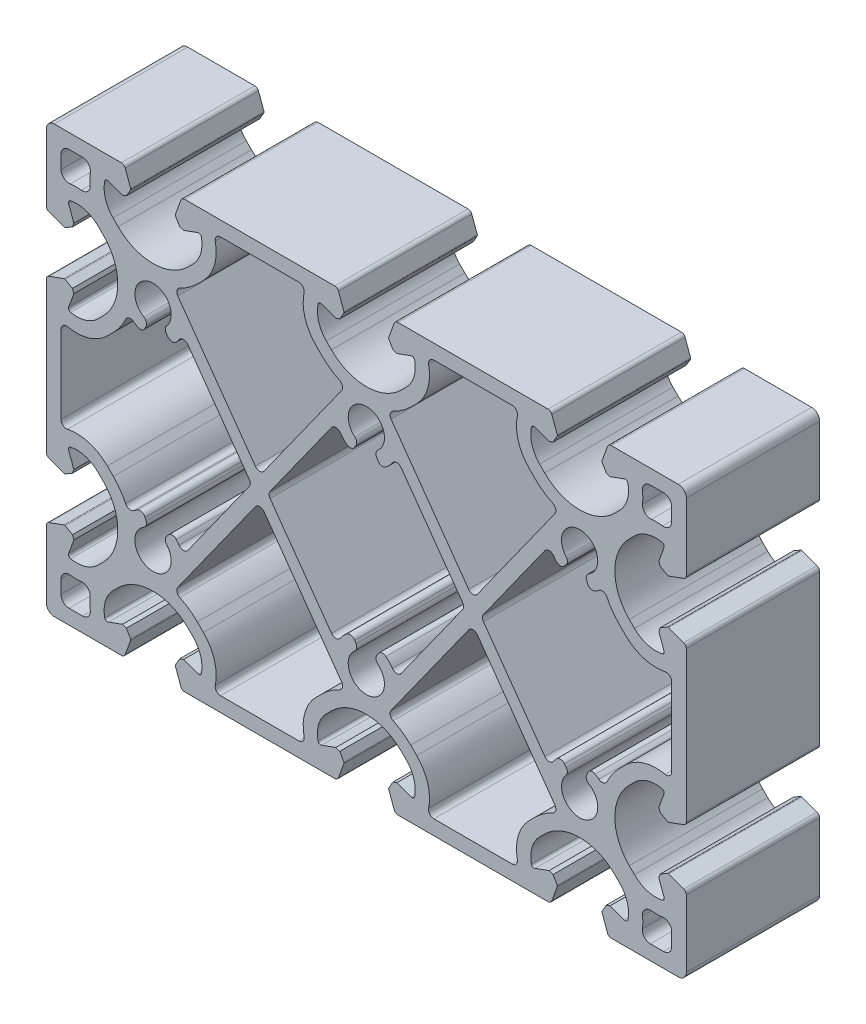
from build123d import *

# Parameters (mm, degrees)
MAIN_EXTRUSION_DEPTH = 25


with BuildPart() as part:
    # Sk Main Extrusion → Main Extrusion (new body)
    with BuildSketch(Plane.XY):
        with BuildLine():
            Line((-35.809923155, -36.671180212), (-34.777945649, -39.506515107))
            ThreePointArc((-34.777945649, -39.506515107), (-34.503358511, -39.864364033), (-34.073176184, -40))
            Line((-34.073176184, -40), (-5.926823816, -40))
            ThreePointArc((-5.926823816, -40), (-5.496641489, -39.864364033), (-5.222054351, -39.506515107))
            Line((-5.222054351, -39.506515107), (-4.190076845, -36.671180212))
            ThreePointArc((-4.190076845, -36.671180212), (-4.175951325, -36.563886241), (-4.208493649, -36.460675177))
            Line((-4.208493649, -36.460675177), (-4.987558066, -35.111296024))
            Line((-4.987558066, -35.111296024), (-5.718509166, -34.845251581))
            Line((-5.718509166, -34.845251581), (-8.396186179, -35.81984631))
            ThreePointArc((-8.396186179, -35.81984631), (-8.811074612, -35.786489799), (-9.056960151, -35.450654467))
            ThreePointArc((-9.056960151, -35.450654467), (-8.933433013, -32.665882372), (-7.504160339, -30.272684887))
            Line((-7.504160339, -30.272684887), (-6.540737726, -29.309262274))
            ThreePointArc((-6.540737726, -29.309262274), (0, -26.6), (6.540737726, -29.309262274))
            Line((6.540737726, -29.309262274), (7.504160339, -30.272684887))
            ThreePointArc((7.504160339, -30.272684887), (8.933433013, -32.665882372), (9.056960151, -35.450654467))
            ThreePointArc((9.056960151, -35.450654467), (8.811074612, -35.786489799), (8.396186179, -35.81984631))
            Line((8.396186179, -35.81984631), (5.718509166, -34.845251581))
            Line((5.718509166, -34.845251581), (4.987558066, -35.111296024))
            Line((4.987558066, -35.111296024), (4.208493649, -36.460675177))
            ThreePointArc((4.208493649, -36.460675177), (4.175951325, -36.563886241), (4.190076845, -36.671180212))
            Line((4.190076845, -36.671180212), (5.222054351, -39.506515107))
            ThreePointArc((5.222054351, -39.506515107), (5.496641489, -39.864364033), (5.926823816, -40))
            Line((5.926823816, -40), (34.073176184, -40))
            ThreePointArc((34.073176184, -40), (34.503358511, -39.864364033), (34.777945649, -39.506515107))
            Line((34.777945649, -39.506515107), (35.809923155, -36.671180212))
            ThreePointArc((35.809923155, -36.671180212), (35.824048675, -36.563886241), (35.791506351, -36.460675176))
            Line((35.791506351, -36.460675176), (35.012441934, -35.111296024))
            Line((35.012441934, -35.111296024), (34.281490834, -34.845251581))
            Line((34.281490834, -34.845251581), (31.603813821, -35.81984631))
            ThreePointArc((31.603813821, -35.81984631), (31.188925388, -35.786489799), (30.943039849, -35.450654467))
            ThreePointArc((30.943039849, -35.450654467), (31.066566987, -32.665882372), (32.495839661, -30.272684887))
            Line((32.495839661, -30.272684887), (33.459262274, -29.309262274))
            ThreePointArc((33.459262274, -29.309262274), (40, -26.6), (46.540737726, -29.309262274))
            Line((46.540737726, -29.309262274), (47.504160339, -30.272684887))
            ThreePointArc((47.504160339, -30.272684887), (48.933433013, -32.665882372), (49.056960151, -35.450654467))
            ThreePointArc((49.056960151, -35.450654467), (48.811074612, -35.786489799), (48.396186179, -35.81984631))
            Line((48.396186179, -35.81984631), (45.718509166, -34.845251581))
            Line((45.718509166, -34.845251581), (44.987558066, -35.111296024))
            Line((44.987558066, -35.111296024), (44.208493649, -36.460675176))
            ThreePointArc((44.208493649, -36.460675176), (44.175951325, -36.563886241), (44.190076845, -36.671180212))
            Line((44.190076845, -36.671180212), (45.222054351, -39.506515107))
            ThreePointArc((45.222054351, -39.506515107), (45.496641489, -39.864364033), (45.926823816, -40))
            Line((45.926823816, -40), (58.5, -40))
            ThreePointArc((58.5, -40), (59.560660172, -39.560660172), (60, -38.5))
            Line((60, -38.5), (60, -25.926823816))
            ThreePointArc((60, -25.926823816), (59.864364033, -25.496641489), (59.506515107, -25.222054351))
            Line((59.506515107, -25.222054351), (56.671180212, -24.190076845))
            ThreePointArc((56.671180212, -24.190076845), (56.563886241, -24.175951325), (56.460675177, -24.208493649))
            Line((56.460675177, -24.208493649), (55.111296024, -24.987558066))
            Line((55.111296024, -24.987558066), (54.845251581, -25.718509166))
            Line((54.845251581, -25.718509166), (55.81984631, -28.396186179))
            ThreePointArc((55.81984631, -28.396186179), (55.786489799, -28.811074612), (55.450654467, -29.056960151))
            ThreePointArc((55.450654467, -29.056960151), (52.665882372, -28.933433013), (50.272684887, -27.504160339))
            Line((50.272684887, -27.504160339), (49.309262274, -26.540737726))
            ThreePointArc((49.309262274, -26.540737726), (46.6, -20), (49.309262274, -13.459262274))
            Line((49.309262274, -13.459262274), (50.272684887, -12.495839661))
            ThreePointArc((50.272684887, -12.495839661), (52.665882372, -11.066566987), (55.450654467, -10.943039849))
            ThreePointArc((55.450654467, -10.943039849), (55.786489799, -11.188925388), (55.81984631, -11.603813821))
            Line((55.81984631, -11.603813821), (54.845251581, -14.281490834))
            Line((54.845251581, -14.281490834), (55.111296024, -15.012441934))
            Line((55.111296024, -15.012441934), (56.460675177, -15.791506351))
            ThreePointArc((56.460675177, -15.791506351), (56.563886241, -15.824048675), (56.671180212, -15.809923155))
            Line((56.671180212, -15.809923155), (59.506515107, -14.777945649))
            ThreePointArc((59.506515107, -14.777945649), (59.864364033, -14.503358511), (60, -14.073176184))
            Line((60, -14.073176184), (60, 14.073176184))
            ThreePointArc((60, 14.073176184), (59.864364033, 14.503358511), (59.506515107, 14.777945649))
            Line((59.506515107, 14.777945649), (56.671180212, 15.809923155))
            ThreePointArc((56.671180212, 15.809923155), (56.563886241, 15.824048675), (56.460675177, 15.791506351))
            Line((56.460675177, 15.791506351), (55.111296024, 15.012441934))
            Line((55.111296024, 15.012441934), (54.845251581, 14.281490834))
            Line((54.845251581, 14.281490834), (55.81984631, 11.603813821))
            ThreePointArc((55.81984631, 11.603813821), (55.786489799, 11.188925388), (55.450654467, 10.943039849))
            ThreePointArc((55.450654467, 10.943039849), (52.665882372, 11.066566987), (50.272684887, 12.495839661))
            Line((50.272684887, 12.495839661), (49.309262274, 13.459262274))
            ThreePointArc((49.309262274, 13.459262274), (46.6, 20), (49.309262274, 26.540737726))
            Line((49.309262274, 26.540737726), (50.272684887, 27.504160339))
            ThreePointArc((50.272684887, 27.504160339), (52.665882372, 28.933433013), (55.450654467, 29.056960151))
            ThreePointArc((55.450654467, 29.056960151), (55.786489799, 28.811074612), (55.81984631, 28.396186179))
            Line((55.81984631, 28.396186179), (54.845251581, 25.718509166))
            Line((54.845251581, 25.718509166), (55.111296024, 24.987558066))
            Line((55.111296024, 24.987558066), (56.460675177, 24.208493649))
            ThreePointArc((56.460675177, 24.208493649), (56.563886241, 24.175951325), (56.671180212, 24.190076845))
            Line((56.671180212, 24.190076845), (59.506515108, 25.222054351))
            ThreePointArc((59.506515108, 25.222054351), (59.864364033, 25.496641489), (60, 25.926823816))
            Line((60, 25.926823816), (60, 38.5))
            ThreePointArc((60, 38.5), (59.560660172, 39.560660172), (58.5, 40))
            Line((58.5, 40), (45.926823816, 40))
            ThreePointArc((45.926823816, 40), (45.496641489, 39.864364033), (45.222054351, 39.506515107))
            Line((45.222054351, 39.506515107), (44.190076845, 36.671180212))
            ThreePointArc((44.190076845, 36.671180212), (44.175951325, 36.563886241), (44.208493649, 36.460675176))
            Line((44.208493649, 36.460675176), (44.987558066, 35.111296024))
            Line((44.987558066, 35.111296024), (45.718509166, 34.845251581))
            Line((45.718509166, 34.845251581), (48.396186179, 35.81984631))
            ThreePointArc((48.396186179, 35.81984631), (48.811074612, 35.786489799), (49.056960151, 35.450654467))
            ThreePointArc((49.056960151, 35.450654467), (48.933433013, 32.665882372), (47.504160339, 30.272684887))
            Line((47.504160339, 30.272684887), (46.540737726, 29.309262274))
            ThreePointArc((46.540737726, 29.309262274), (40, 26.6), (33.459262274, 29.309262274))
            Line((33.459262274, 29.309262274), (32.495839661, 30.272684887))
            ThreePointArc((32.495839661, 30.272684887), (31.066566987, 32.665882372), (30.943039849, 35.450654467))
            ThreePointArc((30.943039849, 35.450654467), (31.188925388, 35.786489799), (31.603813821, 35.81984631))
            Line((31.603813821, 35.81984631), (34.281490834, 34.845251581))
            Line((34.281490834, 34.845251581), (35.012441934, 35.111296024))
            Line((35.012441934, 35.111296024), (35.791506351, 36.460675176))
            ThreePointArc((35.791506351, 36.460675176), (35.824048675, 36.563886241), (35.809923155, 36.671180212))
            Line((35.809923155, 36.671180212), (34.777945649, 39.506515107))
            ThreePointArc((34.777945649, 39.506515107), (34.503358511, 39.864364033), (34.073176184, 40))
            Line((34.073176184, 40), (5.926823816, 40))
            ThreePointArc((5.926823816, 40), (5.496641489, 39.864364033), (5.222054351, 39.506515107))
            Line((5.222054351, 39.506515107), (4.190076845, 36.671180212))
            ThreePointArc((4.190076845, 36.671180212), (4.175951325, 36.563886241), (4.208493649, 36.460675177))
            Line((4.208493649, 36.460675177), (4.987558066, 35.111296024))
            Line((4.987558066, 35.111296024), (5.718509166, 34.845251581))
            Line((5.718509166, 34.845251581), (8.396186179, 35.81984631))
            ThreePointArc((8.396186179, 35.81984631), (8.811074612, 35.786489799), (9.056960151, 35.450654467))
            ThreePointArc((9.056960151, 35.450654467), (8.933433013, 32.665882372), (7.504160339, 30.272684887))
            Line((7.504160339, 30.272684887), (6.540737726, 29.309262274))
            ThreePointArc((6.540737726, 29.309262274), (0, 26.6), (-6.540737726, 29.309262274))
            Line((-6.540737726, 29.309262274), (-7.504160339, 30.272684887))
            ThreePointArc((-7.504160339, 30.272684887), (-8.933433013, 32.665882372), (-9.056960151, 35.450654467))
            ThreePointArc((-9.056960151, 35.450654467), (-8.811074612, 35.786489799), (-8.396186179, 35.81984631))
            Line((-8.396186179, 35.81984631), (-5.718509166, 34.845251581))
            Line((-5.718509166, 34.845251581), (-4.987558066, 35.111296024))
            Line((-4.987558066, 35.111296024), (-4.208493649, 36.460675177))
            ThreePointArc((-4.208493649, 36.460675177), (-4.175951325, 36.563886241), (-4.190076845, 36.671180212))
            Line((-4.190076845, 36.671180212), (-5.222054351, 39.506515107))
            ThreePointArc((-5.222054351, 39.506515107), (-5.496641489, 39.864364033), (-5.926823816, 40))
            Line((-5.926823816, 40), (-34.073176184, 40))
            ThreePointArc((-34.073176184, 40), (-34.503358511, 39.864364033), (-34.777945649, 39.506515107))
            Line((-34.777945649, 39.506515107), (-35.809923155, 36.671180212))
            ThreePointArc((-35.809923155, 36.671180212), (-35.824048675, 36.563886241), (-35.791506351, 36.460675177))
            Line((-35.791506351, 36.460675177), (-35.012441934, 35.111296024))
            Line((-35.012441934, 35.111296024), (-34.281490834, 34.845251581))
            Line((-34.281490834, 34.845251581), (-31.603813821, 35.81984631))
            ThreePointArc((-31.603813821, 35.81984631), (-31.188925388, 35.786489799), (-30.943039849, 35.450654467))
            ThreePointArc((-30.943039849, 35.450654467), (-31.066566987, 32.665882372), (-32.495839661, 30.272684887))
            Line((-32.495839661, 30.272684887), (-33.459262274, 29.309262274))
            ThreePointArc((-33.459262274, 29.309262274), (-40, 26.6), (-46.540737726, 29.309262274))
            Line((-46.540737726, 29.309262274), (-47.504160339, 30.272684887))
            ThreePointArc((-47.504160339, 30.272684887), (-48.933433013, 32.665882372), (-49.056960151, 35.450654467))
            ThreePointArc((-49.056960151, 35.450654467), (-48.811074612, 35.786489799), (-48.396186179, 35.81984631))
            Line((-48.396186179, 35.81984631), (-45.718509166, 34.845251581))
            Line((-45.718509166, 34.845251581), (-44.987558066, 35.111296024))
            Line((-44.987558066, 35.111296024), (-44.208493649, 36.460675177))
            ThreePointArc((-44.208493649, 36.460675177), (-44.175951325, 36.563886241), (-44.190076845, 36.671180212))
            Line((-44.190076845, 36.671180212), (-45.222054351, 39.506515107))
            ThreePointArc((-45.222054351, 39.506515107), (-45.496641489, 39.864364033), (-45.926823816, 40))
            Line((-45.926823816, 40), (-58.5, 40))
            ThreePointArc((-58.5, 40), (-59.560660172, 39.560660172), (-60, 38.5))
            Line((-60, 38.5), (-60, 25.926823816))
            ThreePointArc((-60, 25.926823816), (-59.864364033, 25.496641489), (-59.506515107, 25.222054351))
            Line((-59.506515107, 25.222054351), (-56.671180212, 24.190076845))
            ThreePointArc((-56.671180212, 24.190076845), (-56.563886241, 24.175951325), (-56.460675177, 24.208493649))
            Line((-56.460675177, 24.208493649), (-55.111296024, 24.987558066))
            Line((-55.111296024, 24.987558066), (-54.845251581, 25.718509166))
            Line((-54.845251581, 25.718509166), (-55.81984631, 28.396186179))
            ThreePointArc((-55.81984631, 28.396186179), (-55.786489799, 28.811074612), (-55.450654467, 29.056960151))
            ThreePointArc((-55.450654467, 29.056960151), (-52.665882372, 28.933433013), (-50.272684887, 27.504160339))
            Line((-50.272684887, 27.504160339), (-49.309262274, 26.540737726))
            ThreePointArc((-49.309262274, 26.540737726), (-46.6, 20), (-49.309262274, 13.459262274))
            Line((-49.309262274, 13.459262274), (-50.272684887, 12.495839661))
            ThreePointArc((-50.272684887, 12.495839661), (-52.665882372, 11.066566987), (-55.450654467, 10.943039849))
            ThreePointArc((-55.450654467, 10.943039849), (-55.786489799, 11.188925388), (-55.81984631, 11.603813821))
            Line((-55.81984631, 11.603813821), (-54.845251581, 14.281490834))
            Line((-54.845251581, 14.281490834), (-55.111296024, 15.012441934))
            Line((-55.111296024, 15.012441934), (-56.460675177, 15.791506351))
            ThreePointArc((-56.460675177, 15.791506351), (-56.563886241, 15.824048675), (-56.671180212, 15.809923155))
            Line((-56.671180212, 15.809923155), (-59.506515107, 14.777945649))
            ThreePointArc((-59.506515107, 14.777945649), (-59.864364033, 14.503358511), (-60, 14.073176184))
            Line((-60, 14.073176184), (-60, -14.073176184))
            ThreePointArc((-60, -14.073176184), (-59.864364033, -14.503358511), (-59.506515107, -14.777945649))
            Line((-59.506515107, -14.777945649), (-56.671180212, -15.809923155))
            ThreePointArc((-56.671180212, -15.809923155), (-56.563886241, -15.824048675), (-56.460675177, -15.791506351))
            Line((-56.460675177, -15.791506351), (-55.111296024, -15.012441934))
            Line((-55.111296024, -15.012441934), (-54.845251581, -14.281490834))
            Line((-54.845251581, -14.281490834), (-55.81984631, -11.603813821))
            ThreePointArc((-55.81984631, -11.603813821), (-55.786489799, -11.188925388), (-55.450654467, -10.943039849))
            ThreePointArc((-55.450654467, -10.943039849), (-52.665882372, -11.066566987), (-50.272684887, -12.495839661))
            Line((-50.272684887, -12.495839661), (-49.309262274, -13.459262274))
            ThreePointArc((-49.309262274, -13.459262274), (-46.6, -20), (-49.309262274, -26.540737726))
            Line((-49.309262274, -26.540737726), (-50.272684887, -27.504160339))
            ThreePointArc((-50.272684887, -27.504160339), (-52.665882372, -28.933433013), (-55.450654467, -29.056960151))
            ThreePointArc((-55.450654467, -29.056960151), (-55.786489799, -28.811074612), (-55.81984631, -28.396186179))
            Line((-55.81984631, -28.396186179), (-54.845251581, -25.718509166))
            Line((-54.845251581, -25.718509166), (-55.111296024, -24.987558066))
            Line((-55.111296024, -24.987558066), (-56.460675177, -24.208493649))
            ThreePointArc((-56.460675177, -24.208493649), (-56.563886241, -24.175951325), (-56.671180212, -24.190076845))
            Line((-56.671180212, -24.190076845), (-59.506515107, -25.222054351))
            ThreePointArc((-59.506515107, -25.222054351), (-59.864364033, -25.496641489), (-60, -25.926823816))
            Line((-60, -25.926823816), (-60, -38.5))
            ThreePointArc((-60, -38.5), (-59.560660172, -39.560660172), (-58.5, -40))
            Line((-58.5, -40), (-45.926823816, -40))
            ThreePointArc((-45.926823816, -40), (-45.496641489, -39.864364033), (-45.222054351, -39.506515107))
            Line((-45.222054351, -39.506515107), (-44.190076845, -36.671180212))
            ThreePointArc((-44.190076845, -36.671180212), (-44.175951325, -36.563886241), (-44.208493649, -36.460675177))
            Line((-44.208493649, -36.460675177), (-44.987558066, -35.111296024))
            Line((-44.987558066, -35.111296024), (-45.718509166, -34.845251581))
            Line((-45.718509166, -34.845251581), (-48.396186179, -35.81984631))
            ThreePointArc((-48.396186179, -35.81984631), (-48.811074612, -35.786489799), (-49.056960151, -35.450654467))
            ThreePointArc((-49.056960151, -35.450654467), (-48.933433013, -32.665882372), (-47.504160339, -30.272684887))
            Line((-47.504160339, -30.272684887), (-46.540737726, -29.309262274))
            ThreePointArc((-46.540737726, -29.309262274), (-40, -26.6), (-33.459262274, -29.309262274))
            Line((-33.459262274, -29.309262274), (-32.495839661, -30.272684887))
            ThreePointArc((-32.495839661, -30.272684887), (-31.066566987, -32.665882372), (-30.943039849, -35.450654467))
            ThreePointArc((-30.943039849, -35.450654467), (-31.188925388, -35.786489799), (-31.603813821, -35.81984631))
            Line((-31.603813821, -35.81984631), (-34.281490834, -34.845251581))
            Line((-34.281490834, -34.845251581), (-35.012441934, -35.111296024))
            Line((-35.012441934, -35.111296024), (-35.791506351, -36.460675177))
            ThreePointArc((-35.791506351, -36.460675177), (-35.824048675, -36.563886241), (-35.809923155, -36.671180212))
        make_face()
        with BuildLine():
            Line((-57.25, 35.75), (-57.25, 33.248136122))
            ThreePointArc((-57.25, 33.248136122), (-56.732645411, 32.114818869), (-55.537456006, 31.763270791))
            ThreePointArc((-55.537456006, 31.763270791), (-54.496293642, 31.845117953), (-53.453172645, 31.793965142))
            ThreePointArc((-53.453172645, 31.793965142), (-52.223785121, 32.223785121), (-51.793965142, 33.453172645))
            ThreePointArc((-51.793965142, 33.453172645), (-51.845117953, 34.496293642), (-51.763270791, 35.537456006))
            ThreePointArc((-51.763270791, 35.537456006), (-52.114818869, 36.732645411), (-53.248136122, 37.25))
            Line((-53.248136122, 37.25), (-55.75, 37.25))
            ThreePointArc((-55.75, 37.25), (-56.810660172, 36.810660172), (-57.25, 35.75))
        make_face(mode=Mode.SUBTRACT)
        with BuildLine():
            Line((-30.555717411, 28.577273231), (-31.691495321, 27.441495321))
            ThreePointArc((-31.691495321, 27.441495321), (-33.230868879, 26.145763233), (-34.968742784, 25.131669113))
            ThreePointArc((-34.968742784, 25.131669113), (-35.508458328, 24.479287539), (-35.35428612, 23.646745939))
            Line((-35.35428612, 23.646745939), (-20.813735439, 3.289829278))
            ThreePointArc((-20.813735439, 3.289829278), (-20, 2.871064717), (-19.186264561, 3.289829278))
            Line((-19.186264561, 3.289829278), (-4.64571388, 23.646745939))
            ThreePointArc((-4.64571388, 23.646745939), (-4.491541672, 24.479287539), (-5.031257216, 25.131669113))
            ThreePointArc((-5.031257216, 25.131669113), (-6.769131121, 26.145763233), (-8.308504679, 27.441495321))
            Line((-8.308504679, 27.441495321), (-9.444282589, 28.577273231))
            ThreePointArc((-9.444282589, 28.577273231), (-11.503352502, 32.029888718), (-11.674004236, 36.046255308))
            ThreePointArc((-11.674004236, 36.046255308), (-11.877223969, 36.880973576), (-12.653028291, 37.25))
            Line((-12.653028291, 37.25), (-27.346971709, 37.25))
            ThreePointArc((-27.346971709, 37.25), (-28.122776031, 36.880973576), (-28.325995764, 36.046255308))
            ThreePointArc((-28.325995764, 36.046255308), (-28.496647498, 32.029888718), (-30.555717411, 28.577273231))
        make_face(mode=Mode.SUBTRACT)
        with BuildLine():
            Line((-1.933976199, 16.105894069), (-2.187110328, 15.667452896))
            ThreePointArc((-2.187110328, 15.667452896), (-2.866968019, 15.184936647), (-3.676215879, 15.385302089))
            ThreePointArc((-3.676215879, 15.385302089), (-4.330198405, 15.992584153), (-4.88510203, 16.691559558))
            ThreePointArc((-4.88510203, 16.691559558), (-5.696871998, 17.130675495), (-6.522452454, 16.71811011))
            Line((-6.522452454, 16.71811011), (-18.048709004, 0.581235439))
            ThreePointArc((-18.048709004, 0.581235439), (-18.234973565, 0), (-18.048709004, -0.581235439))
            Line((-18.048709004, -0.581235439), (-6.522452454, -16.71811011))
            ThreePointArc((-6.522452454, -16.71811011), (-5.696871998, -17.130675495), (-4.88510203, -16.691559558))
            ThreePointArc((-4.88510203, -16.691559558), (-4.330198405, -15.992584153), (-3.676215879, -15.385302089))
            ThreePointArc((-3.676215879, -15.385302089), (-2.866968019, -15.184936647), (-2.187110328, -15.667452896))
            Line((-2.187110328, -15.667452896), (-1.933976199, -16.105894069))
            ThreePointArc((-1.933976199, -16.105894069), (-1.815928572, -16.783652203), (-2.163636733, -17.377276971))
            ThreePointArc((-2.163636733, -17.377276971), (0, -23.4), (2.163636733, -17.377276971))
            ThreePointArc((2.163636733, -17.377276971), (1.815928572, -16.783652203), (1.933976199, -16.105894069))
            Line((1.933976199, -16.105894069), (2.187110328, -15.667452896))
            ThreePointArc((2.187110328, -15.667452896), (2.866968019, -15.184936647), (3.676215879, -15.385302089))
            ThreePointArc((3.676215879, -15.385302089), (4.330198405, -15.992584153), (4.88510203, -16.691559558))
            ThreePointArc((4.88510203, -16.691559558), (5.696871998, -17.130675495), (6.522452454, -16.71811011))
            Line((6.522452454, -16.71811011), (18.048709004, -0.581235439))
            ThreePointArc((18.048709004, -0.581235439), (18.234973565, 0), (18.048709004, 0.581235439))
            Line((18.048709004, 0.581235439), (6.522452454, 16.71811011))
            ThreePointArc((6.522452454, 16.71811011), (5.696871998, 17.130675495), (4.88510203, 16.691559558))
            ThreePointArc((4.88510203, 16.691559558), (4.330198405, 15.992584153), (3.676215879, 15.385302089))
            ThreePointArc((3.676215879, 15.385302089), (2.866968019, 15.184936647), (2.187110328, 15.667452896))
            Line((2.187110328, 15.667452896), (1.933976199, 16.105894069))
            ThreePointArc((1.933976199, 16.105894069), (1.815928572, 16.783652203), (2.163636733, 17.377276971))
            ThreePointArc((2.163636733, 17.377276971), (0, 23.4), (-2.163636733, 17.377276971))
            ThreePointArc((-2.163636733, 17.377276971), (-1.815928572, 16.783652203), (-1.933976199, 16.105894069))
        make_face(mode=Mode.SUBTRACT)
        with BuildLine():
            Line((9.444282589, 28.577273231), (8.308504679, 27.441495321))
            ThreePointArc((8.308504679, 27.441495321), (6.769131121, 26.145763233), (5.031257216, 25.131669113))
            ThreePointArc((5.031257216, 25.131669113), (4.491541672, 24.479287539), (4.64571388, 23.646745939))
            Line((4.64571388, 23.646745939), (19.186264561, 3.289829278))
            ThreePointArc((19.186264561, 3.289829278), (20, 2.871064717), (20.813735439, 3.289829278))
            Line((20.813735439, 3.289829278), (35.35428612, 23.646745939))
            ThreePointArc((35.35428612, 23.646745939), (35.508458328, 24.479287539), (34.968742784, 25.131669113))
            ThreePointArc((34.968742784, 25.131669113), (33.230868879, 26.145763233), (31.691495321, 27.441495321))
            Line((31.691495321, 27.441495321), (30.555717411, 28.577273231))
            ThreePointArc((30.555717411, 28.577273231), (28.496647498, 32.029888718), (28.325995764, 36.046255308))
            ThreePointArc((28.325995764, 36.046255308), (28.122776031, 36.880973576), (27.346971709, 37.25))
            Line((27.346971709, 37.25), (12.653028291, 37.25))
            ThreePointArc((12.653028291, 37.25), (11.877223969, 36.880973576), (11.674004236, 36.046255308))
            ThreePointArc((11.674004236, 36.046255308), (11.503352502, 32.029888718), (9.444282589, 28.577273231))
        make_face(mode=Mode.SUBTRACT)
        with BuildLine():
            Line((37.476728113, 16.459171104), (37.157692623, 16.06608858))
            ThreePointArc((37.157692623, 16.06608858), (36.410308442, 15.696694148), (35.642724919, 16.022041495))
            ThreePointArc((35.642724919, 16.022041495), (35.366702333, 16.347254084), (35.11489797, 16.691559558))
            ThreePointArc((35.11489797, 16.691559558), (34.303128002, 17.130675495), (33.477547546, 16.71811011))
            Line((33.477547546, 16.71811011), (21.951290996, 0.581235439))
            ThreePointArc((21.951290996, 0.581235439), (21.765026435, 0), (21.951290996, -0.581235439))
            Line((21.951290996, -0.581235439), (33.477547546, -16.71811011))
            ThreePointArc((33.477547546, -16.71811011), (34.303128002, -17.130675495), (35.11489797, -16.691559558))
            ThreePointArc((35.11489797, -16.691559558), (35.366702333, -16.347254084), (35.642724919, -16.022041495))
            ThreePointArc((35.642724919, -16.022041495), (36.410308442, -15.696694148), (37.157692623, -16.06608858))
            Line((37.157692623, -16.06608858), (37.476728113, -16.459171104))
            ThreePointArc((37.476728113, -16.459171104), (37.700071062, -17.109873787), (37.450217607, -17.750864666))
            ThreePointArc((37.450217607, -17.750864666), (40.535606701, -23.357547537), (41.723459927, -17.069183411))
            ThreePointArc((41.723459927, -17.069183411), (41.286576489, -16.537742993), (41.29638202, -15.84984772))
            Line((41.29638202, -15.84984772), (41.477283726, -15.377013619))
            ThreePointArc((41.477283726, -15.377013619), (42.072644253, -14.793420265), (42.903355818, -14.863802477))
            ThreePointArc((42.903355818, -14.863802477), (43.266861807, -15.086995427), (43.613291925, -15.335868627))
            ThreePointArc((43.613291925, -15.335868627), (44.458362439, -15.517898854), (45.129579832, -14.973154523))
            ThreePointArc((45.129579832, -14.973154523), (46.144357349, -13.232864029), (47.441495321, -11.691495321))
            Line((47.441495321, -11.691495321), (48.577273231, -10.555717411))
            ThreePointArc((48.577273231, -10.555717411), (52.029888718, -8.496647498), (56.046255308, -8.325995764))
            ThreePointArc((56.046255308, -8.325995764), (56.880973576, -8.122776031), (57.25, -7.346971709))
            Line((57.25, -7.346971709), (57.25, 7.346971709))
            ThreePointArc((57.25, 7.346971709), (56.880973576, 8.122776031), (56.046255308, 8.325995764))
            ThreePointArc((56.046255308, 8.325995764), (52.029888718, 8.496647498), (48.577273231, 10.555717411))
            Line((48.577273231, 10.555717411), (47.441495321, 11.691495321))
            ThreePointArc((47.441495321, 11.691495321), (46.144357349, 13.232864029), (45.129579832, 14.973154523))
            ThreePointArc((45.129579832, 14.973154523), (44.458362439, 15.517898854), (43.613291925, 15.335868627))
            ThreePointArc((43.613291925, 15.335868627), (43.266861807, 15.086995427), (42.903355818, 14.863802477))
            ThreePointArc((42.903355818, 14.863802477), (42.072644253, 14.793420265), (41.477283726, 15.377013619))
            Line((41.477283726, 15.377013619), (41.29638202, 15.84984772))
            ThreePointArc((41.29638202, 15.84984772), (41.286576489, 16.537742993), (41.723459927, 17.069183411))
            ThreePointArc((41.723459927, 17.069183411), (40.535606701, 23.357547537), (37.450217607, 17.750864666))
            ThreePointArc((37.450217607, 17.750864666), (37.700071062, 17.109873787), (37.476728113, 16.459171104))
        make_face(mode=Mode.SUBTRACT)
        with BuildLine():
            Line((57.25, 33.248136122), (57.25, 35.75))
            ThreePointArc((57.25, 35.75), (56.810660172, 36.810660172), (55.75, 37.25))
            Line((55.75, 37.25), (53.248136122, 37.25))
            ThreePointArc((53.248136122, 37.25), (52.114818869, 36.732645411), (51.763270791, 35.537456006))
            ThreePointArc((51.763270791, 35.537456006), (51.845117953, 34.496293642), (51.793965142, 33.453172645))
            ThreePointArc((51.793965142, 33.453172645), (52.223785121, 32.223785121), (53.453172645, 31.793965142))
            ThreePointArc((53.453172645, 31.793965142), (54.496293642, 31.845117953), (55.537456006, 31.763270791))
            ThreePointArc((55.537456006, 31.763270791), (56.732645411, 32.114818869), (57.25, 33.248136122))
        make_face(mode=Mode.SUBTRACT)
        with BuildLine():
            Line((-37.157692623, 16.06608858), (-37.476728113, 16.459171104))
            ThreePointArc((-37.476728113, 16.459171104), (-37.700071062, 17.109873787), (-37.450217607, 17.750864666))
            ThreePointArc((-37.450217607, 17.750864666), (-40.535606701, 23.357547537), (-41.723459927, 17.069183411))
            ThreePointArc((-41.723459927, 17.069183411), (-41.286576489, 16.537742993), (-41.29638202, 15.84984772))
            Line((-41.29638202, 15.84984772), (-41.477283726, 15.377013619))
            ThreePointArc((-41.477283726, 15.377013619), (-42.072644253, 14.793420265), (-42.903355818, 14.863802477))
            ThreePointArc((-42.903355818, 14.863802477), (-43.266861807, 15.086995427), (-43.613291925, 15.335868627))
            ThreePointArc((-43.613291925, 15.335868627), (-44.458362439, 15.517898854), (-45.129579832, 14.973154523))
            ThreePointArc((-45.129579832, 14.973154523), (-46.144357349, 13.232864029), (-47.441495321, 11.691495321))
            Line((-47.441495321, 11.691495321), (-48.577273231, 10.555717411))
            ThreePointArc((-48.577273231, 10.555717411), (-52.029888718, 8.496647498), (-56.046255308, 8.325995764))
            ThreePointArc((-56.046255308, 8.325995764), (-56.880973576, 8.122776031), (-57.25, 7.346971709))
            Line((-57.25, 7.346971709), (-57.25, -7.346971709))
            ThreePointArc((-57.25, -7.346971709), (-56.880973576, -8.122776031), (-56.046255308, -8.325995764))
            ThreePointArc((-56.046255308, -8.325995764), (-52.029888718, -8.496647498), (-48.577273231, -10.555717411))
            Line((-48.577273231, -10.555717411), (-47.441495321, -11.691495321))
            ThreePointArc((-47.441495321, -11.691495321), (-46.144357349, -13.232864029), (-45.129579832, -14.973154523))
            ThreePointArc((-45.129579832, -14.973154523), (-44.458362439, -15.517898854), (-43.613291925, -15.335868627))
            ThreePointArc((-43.613291925, -15.335868627), (-43.266861807, -15.086995427), (-42.903355818, -14.863802477))
            ThreePointArc((-42.903355818, -14.863802477), (-42.072644253, -14.793420265), (-41.477283726, -15.377013619))
            Line((-41.477283726, -15.377013619), (-41.29638202, -15.84984772))
            ThreePointArc((-41.29638202, -15.84984772), (-41.286576489, -16.537742993), (-41.723459927, -17.069183411))
            ThreePointArc((-41.723459927, -17.069183411), (-40.535606701, -23.357547537), (-37.450217607, -17.750864666))
            ThreePointArc((-37.450217607, -17.750864666), (-37.700071062, -17.109873787), (-37.476728113, -16.459171104))
            Line((-37.476728113, -16.459171104), (-37.157692623, -16.06608858))
            ThreePointArc((-37.157692623, -16.06608858), (-36.410308442, -15.696694148), (-35.642724919, -16.022041495))
            ThreePointArc((-35.642724919, -16.022041495), (-35.366702333, -16.347254084), (-35.11489797, -16.691559558))
            ThreePointArc((-35.11489797, -16.691559558), (-34.303128002, -17.130675495), (-33.477547546, -16.71811011))
            Line((-33.477547546, -16.71811011), (-21.951290996, -0.581235439))
            ThreePointArc((-21.951290996, -0.581235439), (-21.765026435, 0), (-21.951290996, 0.581235439))
            Line((-21.951290996, 0.581235439), (-33.477547546, 16.71811011))
            ThreePointArc((-33.477547546, 16.71811011), (-34.303128002, 17.130675495), (-35.11489797, 16.691559558))
            ThreePointArc((-35.11489797, 16.691559558), (-35.366702333, 16.347254084), (-35.642724919, 16.022041495))
            ThreePointArc((-35.642724919, 16.022041495), (-36.410308442, 15.696694148), (-37.157692623, 16.06608858))
        make_face(mode=Mode.SUBTRACT)
        with BuildLine():
            Line((-57.25, -33.248136122), (-57.25, -35.75))
            ThreePointArc((-57.25, -35.75), (-56.810660172, -36.810660172), (-55.75, -37.25))
            Line((-55.75, -37.25), (-53.248136122, -37.25))
            ThreePointArc((-53.248136122, -37.25), (-52.114818869, -36.732645411), (-51.763270791, -35.537456006))
            ThreePointArc((-51.763270791, -35.537456006), (-51.845117953, -34.496293642), (-51.793965142, -33.453172645))
            ThreePointArc((-51.793965142, -33.453172645), (-52.223785121, -32.223785121), (-53.453172645, -31.793965142))
            ThreePointArc((-53.453172645, -31.793965142), (-54.496293642, -31.845117953), (-55.537456006, -31.763270791))
            ThreePointArc((-55.537456006, -31.763270791), (-56.732645411, -32.114818869), (-57.25, -33.248136122))
        make_face(mode=Mode.SUBTRACT)
        with BuildLine():
            Line((-4.64571388, -23.646745939), (-19.186264561, -3.289829278))
            ThreePointArc((-19.186264561, -3.289829278), (-20, -2.871064717), (-20.813735439, -3.289829278))
            Line((-20.813735439, -3.289829278), (-35.35428612, -23.646745939))
            ThreePointArc((-35.35428612, -23.646745939), (-35.508458328, -24.479287539), (-34.968742784, -25.131669113))
            ThreePointArc((-34.968742784, -25.131669113), (-33.230868879, -26.145763233), (-31.691495321, -27.441495321))
            Line((-31.691495321, -27.441495321), (-30.555717411, -28.577273231))
            ThreePointArc((-30.555717411, -28.577273231), (-28.496647498, -32.029888718), (-28.325995764, -36.046255308))
            ThreePointArc((-28.325995764, -36.046255308), (-28.122776031, -36.880973576), (-27.346971709, -37.25))
            Line((-27.346971709, -37.25), (-12.653028291, -37.25))
            ThreePointArc((-12.653028291, -37.25), (-11.877223969, -36.880973576), (-11.674004236, -36.046255308))
            ThreePointArc((-11.674004236, -36.046255308), (-11.503352502, -32.029888718), (-9.444282589, -28.577273231))
            Line((-9.444282589, -28.577273231), (-8.308504679, -27.441495321))
            ThreePointArc((-8.308504679, -27.441495321), (-6.769131121, -26.145763233), (-5.031257216, -25.131669113))
            ThreePointArc((-5.031257216, -25.131669113), (-4.491541672, -24.479287539), (-4.64571388, -23.646745939))
        make_face(mode=Mode.SUBTRACT)
        with BuildLine():
            Line((8.308504679, -27.441495321), (9.444282589, -28.577273231))
            ThreePointArc((9.444282589, -28.577273231), (11.503352502, -32.029888718), (11.674004236, -36.046255308))
            ThreePointArc((11.674004236, -36.046255308), (11.877223969, -36.880973576), (12.653028291, -37.25))
            Line((12.653028291, -37.25), (27.346971709, -37.25))
            ThreePointArc((27.346971709, -37.25), (28.122776031, -36.880973576), (28.325995764, -36.046255308))
            ThreePointArc((28.325995764, -36.046255308), (28.496647498, -32.029888718), (30.555717411, -28.577273231))
            Line((30.555717411, -28.577273231), (31.691495321, -27.441495321))
            ThreePointArc((31.691495321, -27.441495321), (33.230868879, -26.145763233), (34.968742784, -25.131669113))
            ThreePointArc((34.968742784, -25.131669113), (35.508458328, -24.479287539), (35.35428612, -23.646745939))
            Line((35.35428612, -23.646745939), (20.813735439, -3.289829278))
            ThreePointArc((20.813735439, -3.289829278), (20, -2.871064717), (19.186264561, -3.289829278))
            Line((19.186264561, -3.289829278), (4.64571388, -23.646745939))
            ThreePointArc((4.64571388, -23.646745939), (4.491541672, -24.479287539), (5.031257216, -25.131669113))
            ThreePointArc((5.031257216, -25.131669113), (6.769131121, -26.145763233), (8.308504679, -27.441495321))
        make_face(mode=Mode.SUBTRACT)
        with BuildLine():
            Line((57.25, -35.75), (57.25, -33.248136122))
            ThreePointArc((57.25, -33.248136122), (56.732645411, -32.114818869), (55.537456006, -31.763270791))
            ThreePointArc((55.537456006, -31.763270791), (54.496293642, -31.845117953), (53.453172645, -31.793965142))
            ThreePointArc((53.453172645, -31.793965142), (52.223785121, -32.223785121), (51.793965142, -33.453172645))
            ThreePointArc((51.793965142, -33.453172645), (51.845117953, -34.496293642), (51.763270791, -35.537456006))
            ThreePointArc((51.763270791, -35.537456006), (52.114818869, -36.732645411), (53.248136122, -37.25))
            Line((53.248136122, -37.25), (55.75, -37.25))
            ThreePointArc((55.75, -37.25), (56.810660172, -36.810660172), (57.25, -35.75))
        make_face(mode=Mode.SUBTRACT)
    extrude(amount=-MAIN_EXTRUSION_DEPTH)


solid = part.part
